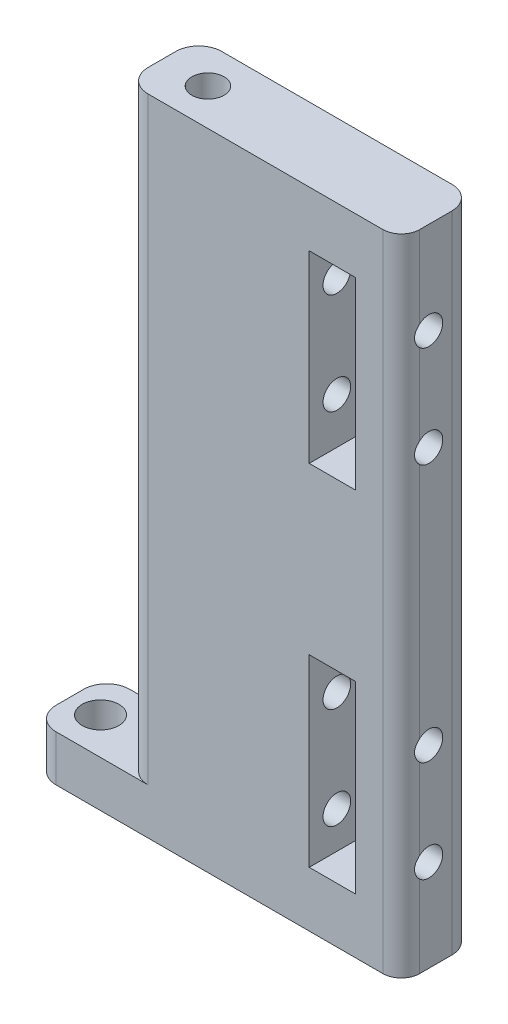
from build123d import *

# Parameters (mm, degrees)
ESBO_O2_W                = 30
ESBO_O2_H                = 70
RESSALTO_EXTRUS_O1_DEPTH = 8
ESBO_O3_R                = 0.75
CORTE_EXTRUS_O1_DEPTH    = 30
FILETE1_R                = 2
ESBO_O17_W               = 10
ESBO_O17_H               = 5
RESSALTO_EXTRUS_O4_DEPTH = 8
ESBO_O20_R               = 2
CORTE_EXTRUS_O9_DEPTH    = 8
FILETE2_R                = 2.5
FILETE3_R                = 2.5
FILETE4_R                = 2.5
FILETE5_R                = 2.5
ESBO_O21_W               = 5
ESBO_O21_H               = 20
CORTE_EXTRUS_O10_DEPTH   = 9
FILETE6_R                = 2.5
ESBO_O22_R               = 1.5
CORTE_EXTRUS_O11_DEPTH   = 20
ESBO_O23_R               = 1.75
CORTE_EXTRUS_O12_DEPTH   = 22


with BuildPart() as part:
    # Esboço2 → Ressalto-extrusão1 (new body)
    with BuildSketch(Plane.XY):
        with Locations((-52.281248797, -0.107598663)):
            Rectangle(ESBO_O2_W, ESBO_O2_H)
    extrude(amount=RESSALTO_EXTRUS_O1_DEPTH)

    # Esboço3 → Corte-extrusão1 (cut)
    with BuildSketch(Plane(origin=(0, -35.107598663, 0), x_dir=(-1, 0, 0), z_dir=(0, -1, 0))):
        with Locations((58.281248797, -4)):
            Circle(ESBO_O3_R)
        with Locations((63.281248797, -4)):
            Circle(ESBO_O3_R)
    extrude(amount=-CORTE_EXTRUS_O1_DEPTH, mode=Mode.SUBTRACT)

    # Filete1
    filete1_edges = [part.edges().sort_by_distance(p)[0] for p in [
        (-37.281248797, -0.107598663, 8),
    ]]
    fillet(filete1_edges, radius=FILETE1_R)

    # Esboço17 → Ressalto-extrusão4 (add)
    with BuildSketch(Plane(origin=(0, 0, 0), x_dir=(-1, 0, 0), z_dir=(0, 0, -1))):
        with Locations((72.281248797, -32.607598663)):
            Rectangle(ESBO_O17_W, ESBO_O17_H)
    extrude(amount=-RESSALTO_EXTRUS_O4_DEPTH)

    # Esboço20 → Corte-extrusão9 (cut)
    with BuildSketch(Plane.XZ.offset(35.107598663)):
        with Locations((-73.951248797, 4)):
            Circle(ESBO_O20_R)
    extrude(amount=-CORTE_EXTRUS_O9_DEPTH, mode=Mode.SUBTRACT)

    # Filete2
    filete2_edges = [part.edges().sort_by_distance(p)[0] for p in [
        (-67.281248797, 2.392401337, 8),
    ]]
    fillet(filete2_edges, radius=FILETE2_R)

    # Filete3
    filete3_edges = [part.edges().sort_by_distance(p)[0] for p in [
        (-67.281248797, 2.392401337, 0),
    ]]
    fillet(filete3_edges, radius=FILETE3_R)

    # Filete4
    filete4_edges = [part.edges().sort_by_distance(p)[0] for p in [
        (-77.281248797, -32.607598663, 8),
    ]]
    fillet(filete4_edges, radius=FILETE4_R)

    # Filete5
    filete5_edges = [part.edges().sort_by_distance(p)[0] for p in [
        (-77.281248797, -32.607598663, 0),
    ]]
    fillet(filete5_edges, radius=FILETE5_R)

    # Esboço21 → Corte-extrusão10 (cut, through all)
    with BuildSketch(Plane.XY.offset(8)):
        with Locations((-44.781248797, 18.892401337)):
            Rectangle(ESBO_O21_W, ESBO_O21_H)
        with Locations((-44.781248797, -19.107598663)):
            Rectangle(ESBO_O21_W, ESBO_O21_H)
    extrude(amount=-CORTE_EXTRUS_O10_DEPTH, mode=Mode.SUBTRACT)

    # Filete6
    filete6_edges = [part.edges().sort_by_distance(p)[0] for p in [
        (-37.281248797, -0.107598663, 0),
    ]]
    fillet(filete6_edges, radius=FILETE6_R)

    # Esboço22 → Corte-extrusão11 (cut)
    with BuildSketch(Plane(origin=(-37.281248797, 0, 0), x_dir=(0, 0, -1), z_dir=(1, 0, 0))):
        with Locations((-5, -25.107598663)):
            Circle(ESBO_O22_R)
        with Locations((-5, -14.107598663)):
            Circle(ESBO_O22_R)
        with Locations((-5, 24.892401337)):
            Circle(ESBO_O22_R)
        with Locations((-5, 13.892401337)):
            Circle(ESBO_O22_R)
    extrude(amount=-CORTE_EXTRUS_O11_DEPTH, mode=Mode.SUBTRACT)

    # Esboço23 → Corte-extrusão12 (cut)
    with BuildSketch(Plane(origin=(0, 34.892401337, 0), x_dir=(1, 0, 0), z_dir=(0, 1, 0))):
        with Locations((-62.281248797, -4)):
            Circle(ESBO_O23_R)
    extrude(amount=-CORTE_EXTRUS_O12_DEPTH, mode=Mode.SUBTRACT)


solid = part.part
